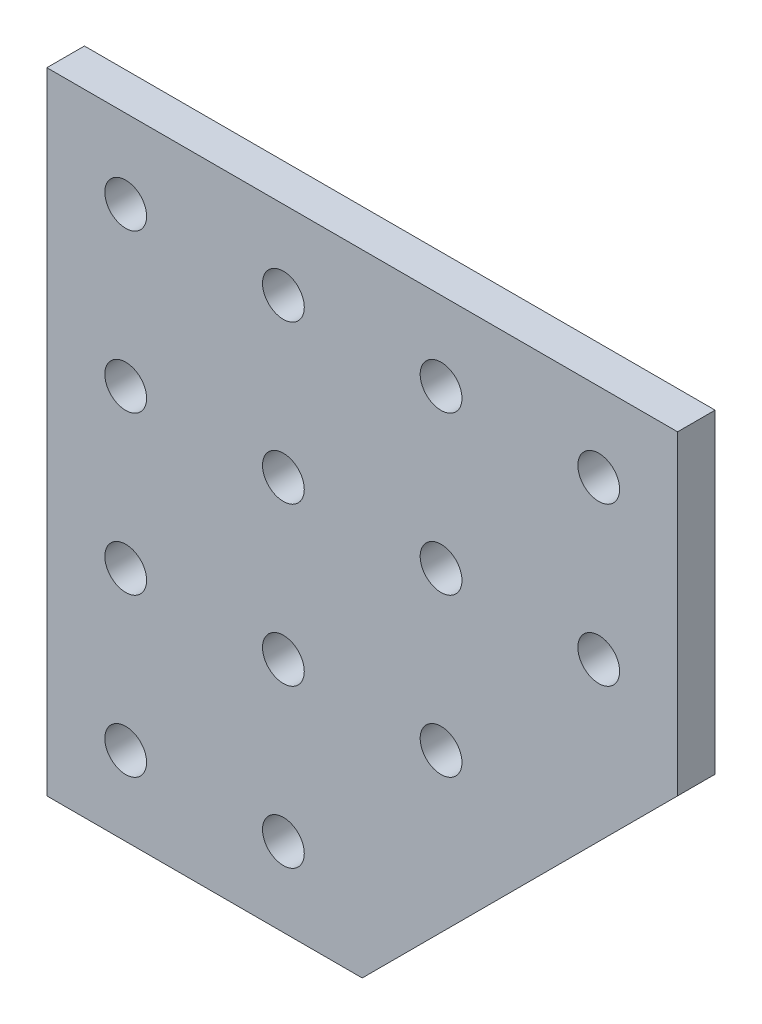
from build123d import *

# Parameters (mm, degrees)
SKETCH1_W            = 40
SKETCH1_H            = 40
BOSS_EXTRUDE1_DEPTH  = 4.7625
M5_CLEARANCE_HOLE1_D = 5.3


with BuildPart() as part:
    # Sketch1 → Boss-Extrude1 (new body)
    with BuildSketch(Plane.XY):
        with Locations((20, 20)):
            Rectangle(SKETCH1_W, SKETCH1_H)
        with Locations((20, 60)):
            Rectangle(SKETCH1_W, SKETCH1_H)
        with Locations((60, 60)):
            Rectangle(SKETCH1_W, SKETCH1_H)
        Polygon((40, 40), (40, 0), (80, 40), align=None)
    extrude(amount=BOSS_EXTRUDE1_DEPTH)

    # M5 Clearance Hole1 (through all)
    with Locations(Plane.XY.offset(4.7625)):
        with Locations((10, 70), (30, 70), (50, 70), (70, 70), (30, 50), (50, 50), (70, 50), (30, 30), (50, 30), (30, 10), (10, 50), (10, 30), (10, 10)):
            Hole(M5_CLEARANCE_HOLE1_D / 2)


solid = part.part
